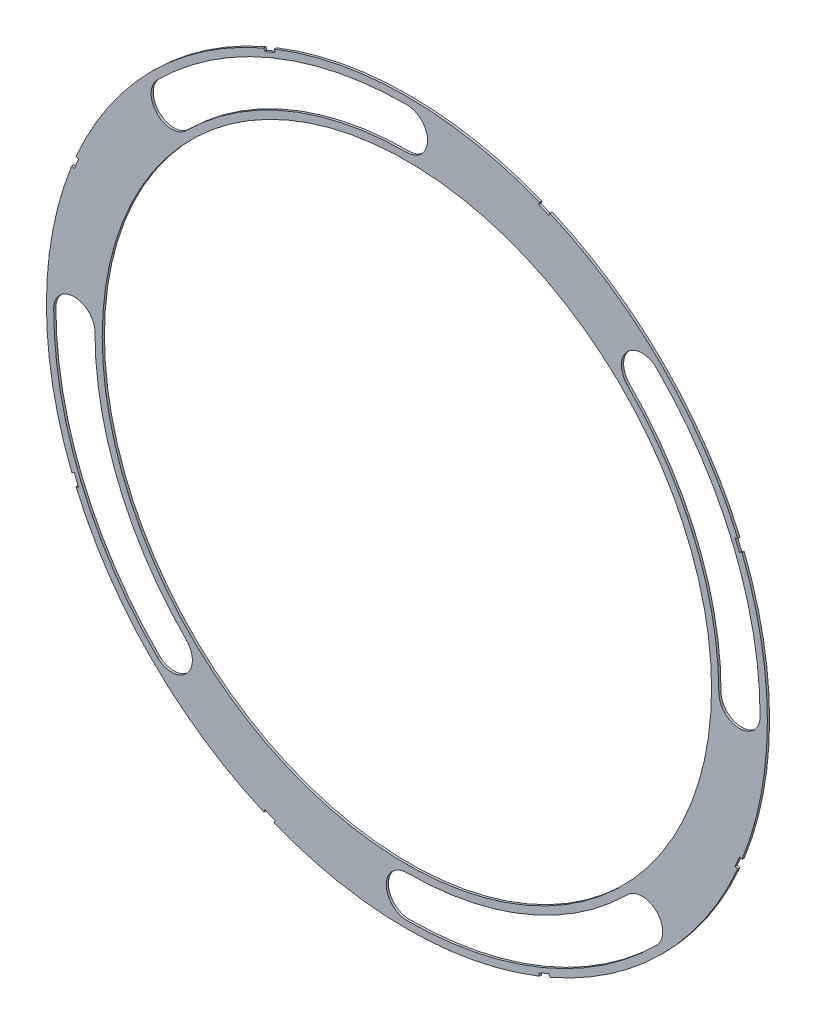
from build123d import *

# Parameters (mm, degrees)
SKETCH4_R           = 82.042
BOSS_EXTRUDE2_DEPTH = 0.508
SKETCH5_R           = 69.342
CUT_EXTRUDE5_DEPTH  = 1.508
CUT_EXTRUDE6_DEPTH  = 1.508
CUT_EXTRUDE11_DEPTH = 1.508


with BuildPart() as part:
    # Sketch4 → Boss-Extrude2 (new body)
    with BuildSketch(Plane.XY):
        Circle(SKETCH4_R)
    extrude(amount=BOSS_EXTRUDE2_DEPTH)

    # Sketch5 → Cut-Extrude5 (cut, through all)
    with BuildSketch(Plane.XY.offset(0.508)):
        Circle(SKETCH5_R)
    extrude(amount=-CUT_EXTRUDE5_DEPTH, mode=Mode.SUBTRACT)

    # Sketch6 → Cut-Extrude6 (cut, through all)
    with BuildSketch(Plane.XY.offset(0.508)):
        with BuildLine():
            ThreePointArc((56.845021902, 56.845020591), (50.199631755, 56.845021285), (50.199632296, 50.199631138))
            ThreePointArc((50.199632296, 50.199631138), (65.588979611, 27.167845011), (70.993, 1.03e-06))
            ThreePointArc((70.993, 1.03e-06), (75.692000068, -4.699), (80.391, 1.166e-06))
            ThreePointArc((80.391, 1.166e-06), (74.271599452, 30.764303922), (56.845021902, 56.845020591))
        make_face()
        with BuildLine():
            ThreePointArc((56.845020591, -56.845021902), (56.845021285, -50.199631755), (50.199631138, -50.199632296))
            ThreePointArc((50.199631138, -50.199632296), (27.167845011, -65.588979611), (1.03e-06, -70.993))
            ThreePointArc((1.03e-06, -70.993), (-4.699, -75.692000068), (1.166e-06, -80.391))
            ThreePointArc((1.166e-06, -80.391), (30.764303922, -74.271599452), (56.845020591, -56.845021902))
        make_face()
        with BuildLine():
            ThreePointArc((-56.845021902, -56.845020591), (-50.199631755, -56.845021285), (-50.199632296, -50.199631138))
            ThreePointArc((-50.199632296, -50.199631138), (-65.588979611, -27.167845011), (-70.993, -1.03e-06))
            ThreePointArc((-70.993, -1.03e-06), (-75.692000068, 4.699), (-80.391, -1.166e-06))
            ThreePointArc((-80.391, -1.166e-06), (-74.271599452, -30.764303922), (-56.845021902, -56.845020591))
        make_face()
        with BuildLine():
            ThreePointArc((-56.845020591, 56.845021902), (-56.845021285, 50.199631755), (-50.199631138, 50.199632296))
            ThreePointArc((-50.199631138, 50.199632296), (-27.167845011, 65.588979611), (-1.03e-06, 70.993))
            ThreePointArc((-1.03e-06, 70.993), (4.699, 75.692000068), (-1.166e-06, 80.391))
            ThreePointArc((-1.166e-06, 80.391), (-30.764303922, 74.271599452), (-56.845020591, 56.845021902))
        make_face()
    extrude(amount=-CUT_EXTRUDE6_DEPTH, mode=Mode.SUBTRACT)

    # Sketch8 → Cut-Extrude11 (cut, through all)
    with BuildSketch(Plane.XY.offset(0.508)):
        Polygon((76.869596069, 30.465791131), (75.89758015, 32.812445144), (74.724253144, 32.326437185), (75.696269062, 29.979783172), align=None)
        Polygon((-30.465791131, 76.869596069), (-32.812445144, 75.89758015), (-32.326437185, 74.724253144), (-29.979783172, 75.696269062), align=None)
        Polygon((-75.89758015, 32.812445144), (-76.869596069, 30.465791131), (-75.696269062, 29.979783172), (-74.724253144, 32.326437185), align=None)
        Polygon((-76.869596069, -30.465791131), (-75.89758015, -32.812445144), (-74.724253144, -32.326437185), (-75.696269062, -29.979783172), align=None)
        Polygon((-32.812445144, -75.89758015), (-30.465791131, -76.869596069), (-29.979783172, -75.696269062), (-32.326437185, -74.724253144), align=None)
        Polygon((30.465791131, -76.869596069), (32.812445144, -75.89758015), (32.326437185, -74.724253144), (29.979783172, -75.696269062), align=None)
        Polygon((75.89758015, -32.812445144), (76.869596069, -30.465791131), (75.696269062, -29.979783172), (74.724253144, -32.326437185), align=None)
        Polygon((32.812445144, 75.89758015), (30.465791131, 76.869596069), (29.979783172, 75.696269062), (32.326437185, 74.724253144), align=None)
    extrude(amount=-CUT_EXTRUDE11_DEPTH, mode=Mode.SUBTRACT)


solid = part.part
